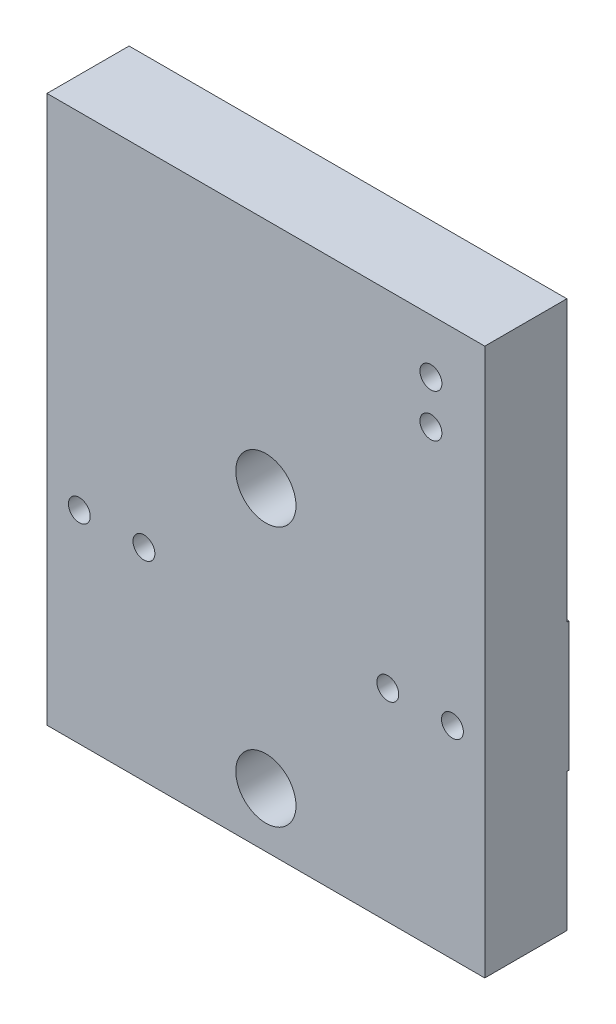
from build123d import *

# Parameters (mm, degrees)
SKETCH1_W         = 20.32
SKETCH1_H         = 25.4
SKETCH1_R         = 1.397
SKETCH1_R_2       = 0.508
SKETCH1_R_3       = 0.51
BOARD_DEPTH       = 3.81
SKETCH2_W         = 3
SKETCH2_H         = 6
SKETCH2_R         = 0.508
SKETCH2_R_2       = 1.008
SKETCH2_R_3       = 0.81
SKETCH2_R_4       = 0.51
SKETCH2_W_2       = 1.5
SKETCH2_H_2       = 0.4
SKETCH2_W_3       = 0.4
SKETCH2_H_3       = 1.475523652
SOLDER_PADS_DEPTH = 0.1


with BuildPart() as part:
    # Sketch1 → Board (new body)
    with BuildSketch(Plane.XY):
        Rectangle(SKETCH1_W, SKETCH1_H)
        with Locations((0, -10.16)):
            Circle(SKETCH1_R, mode=Mode.SUBTRACT)
        with Locations((0, 1.905)):
            Circle(SKETCH1_R, mode=Mode.SUBTRACT)
        with Locations((-8.66, -3.302)):
            Circle(SKETCH1_R_2, mode=Mode.SUBTRACT)
        with Locations((8.66, -3.302)):
            Circle(SKETCH1_R_2, mode=Mode.SUBTRACT)
        with Locations((-5.66, -3.302)):
            Circle(SKETCH1_R_2, mode=Mode.SUBTRACT)
        with Locations((5.66, -3.302)):
            Circle(SKETCH1_R_2, mode=Mode.SUBTRACT)
        with Locations((7.66, 10.2)):
            Circle(SKETCH1_R_3, mode=Mode.SUBTRACT)
        with Locations((7.66, 8.2)):
            Circle(SKETCH1_R_3, mode=Mode.SUBTRACT)
    extrude(amount=BOARD_DEPTH)

    # Sketch2 → Solder Pads (add)
    with BuildSketch(Plane.XY):
        with Locations((8.66, -3.302)):
            Rectangle(SKETCH2_W, SKETCH2_H)
        with Locations((8.66, -3.302)):
            Circle(SKETCH2_R, mode=Mode.SUBTRACT)
        with Locations((-8.66, -3.302)):
            Rectangle(SKETCH2_W, SKETCH2_H)
        with Locations((-8.66, -3.302)):
            Circle(SKETCH2_R, mode=Mode.SUBTRACT)
        with Locations((5.66, -3.302)):
            Circle(SKETCH2_R_2)
        with Locations((5.66, -3.302)):
            Circle(SKETCH2_R, mode=Mode.SUBTRACT)
        with Locations((-5.66, -3.302)):
            Circle(SKETCH2_R_2)
        with Locations((-5.66, -3.302)):
            Circle(SKETCH2_R, mode=Mode.SUBTRACT)
        with Locations((7.66, 8.2)):
            Circle(SKETCH2_R_3)
        with Locations((7.66, 8.2)):
            Circle(SKETCH2_R_4, mode=Mode.SUBTRACT)
        with Locations((7.66, 10.2)):
            Circle(SKETCH2_R_3)
        with Locations((7.66, 10.2)):
            Circle(SKETCH2_R_4, mode=Mode.SUBTRACT)
        with Locations((7.91, 0.598)):
            Rectangle(SKETCH2_W_2, SKETCH2_H_2)
        with Locations((7.91, 0.575572986)):
            Rectangle(SKETCH2_W_3, SKETCH2_H_3)
        with Locations((-7.91, 0.598)):
            Rectangle(SKETCH2_W_2, SKETCH2_H_2)
    extrude(amount=-SOLDER_PADS_DEPTH)


solid = part.part
